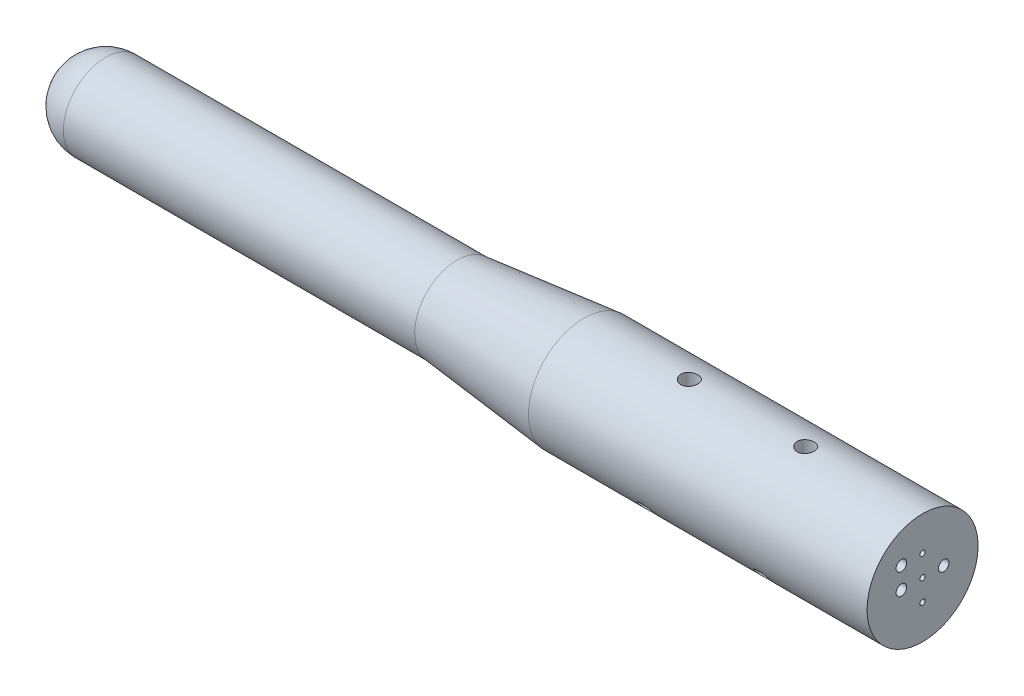
from build123d import *

# Parameters (mm, degrees)
SKETCH3_R                             = 0.79375
CUT_EXTRUDE1_DEPTH                    = 258.810003035
SKETCH4_R                             = 1.5875
CUT_EXTRUDE2_DEPTH                    = 12.7
TAP_DRILL_FOR_10_HELICOIL2_AT_2_COUNT = 2
TAP_DRILL_FOR_10_HELICOIL2_AT_2_PITCH = 34.925
CIRPATTERN2_COUNT                     = 3
CIRPATTERN2_ANGLE                     = 230
SKETCH11_R                            = 1.5875
CUT_EXTRUDE3_DEPTH                    = 12.7


with BuildPart() as part:
    # Sketch1 → Revolve1 (revolve)
    with BuildSketch(Plane.XY):
        with BuildLine():
            Line((12.7, 12.7), (118.11, 12.7))
            Line((118.11, 12.7), (156.210003035, 16.662289952))
            Line((156.210003035, 16.662289952), (257.810003035, 16.662289952))
            Line((257.810003035, 16.662289952), (257.810003035, 0))
            Line((257.810003035, 0), (0, 0))
            ThreePointArc((0, 0), (3.719743879, 8.980256121), (12.7, 12.7))
        make_face()
    revolve(axis=Axis((0, 0, 0), (1, 0, 0)))

    # Sketch3 → Cut-Extrude1 (cut, through all)
    with BuildSketch(Plane(origin=(257.810003035, 0, 0), x_dir=(0, 0, -1), z_dir=(1, 0, 0))):
        Circle(SKETCH3_R)
        with Locations((6.35, 0)):
            Circle(SKETCH3_R)
        with Locations((-6.35, 0)):
            Circle(SKETCH3_R)
        with Locations((0, 6.35)):
            Circle(SKETCH3_R)
        with Locations((0, -6.35)):
            Circle(SKETCH3_R)
    extrude(amount=-CUT_EXTRUDE1_DEPTH, mode=Mode.SUBTRACT)

    # Sketch4 → Cut-Extrude2 (cut)
    with BuildSketch(Plane(origin=(257.810003035, 0, 0), x_dir=(0, 0, -1), z_dir=(1, 0, 0))):
        with Locations((-6.35, 0)):
            Circle(SKETCH4_R)
        with Locations((6.35, 0)):
            Circle(SKETCH4_R)
    extrude(amount=-CUT_EXTRUDE2_DEPTH, mode=Mode.SUBTRACT)

    # Sketch8 → Tap Drill for #10 Helicoil2 (revolve, cut)
    with BuildSketch(Plane(origin=(222.758003035, 16.662289952, 0), x_dir=(0, 0, 1), z_dir=(1, 0, 0))):
        Polygon((0, 0), (0, 8.3312), (2.5527, 6.797383098), (2.5527, 0), align=None)
    tap_drill_for_10_helicoil2 = revolve(axis=Axis((222.758003035, 23.012289952, 0), (0, -1, 0)), mode=Mode.SUBTRACT)

    # Tap Drill for #10 Helicoil2 at 2: Tap Drill for #10 Helicoil2 ×2
    with Locations(*[(-i * TAP_DRILL_FOR_10_HELICOIL2_AT_2_PITCH, 0, 0) for i in range(1, TAP_DRILL_FOR_10_HELICOIL2_AT_2_COUNT)]):
        add(tap_drill_for_10_helicoil2, mode=Mode.SUBTRACT)

    # CirPattern2: Tap Drill for #10 Helicoil2 ×3 about axis
    cirpattern2_axis = Axis((257.810003035, 0, 0), (-1, 0, 0))
    for i in range(1, CIRPATTERN2_COUNT):
        add(tap_drill_for_10_helicoil2.rotate(cirpattern2_axis, i * CIRPATTERN2_ANGLE / (CIRPATTERN2_COUNT - 1)), mode=Mode.SUBTRACT)

    # CirPattern2 copy 1 sketch → CirPattern2 copy 1 (revolve, cut)
    with BuildSketch(Plane(origin=(187.833003035, -7.041788016, -15.101163133), x_dir=(0, 0.906307787, -0.422618262), z_dir=(1, 0, 0))):
        Polygon((0, 0), (0, 8.3312), (2.5527, 6.797383098), (2.5527, 0), align=None)
    revolve(axis=Axis((187.833003035, -9.725413978, -20.856217581), (0, 0.422618262, 0.906307787)), mode=Mode.SUBTRACT)

    # CirPattern2 copy 2 sketch → CirPattern2 copy 2 (revolve, cut)
    with BuildSketch(Plane(origin=(187.833003035, -10.71031353, 12.764054627), x_dir=(0, -0.766044443, -0.64278761), z_dir=(1, 0, 0))):
        Polygon((0, 0), (0, 8.3312), (2.5527, 6.797383098), (2.5527, 0), align=None)
    revolve(axis=Axis((187.833003035, -14.792014851, 17.628436841), (0, 0.64278761, -0.766044443)), mode=Mode.SUBTRACT)

    # Sketch11 → Cut-Extrude3 (cut)
    with BuildSketch(Plane(origin=(257.810003035, 0, 0), x_dir=(0, 0, -1), z_dir=(1, 0, 0))):
        with Locations((-6.35, 6.35)):
            Circle(SKETCH11_R)
    extrude(amount=-CUT_EXTRUDE3_DEPTH, mode=Mode.SUBTRACT)


solid = part.part
